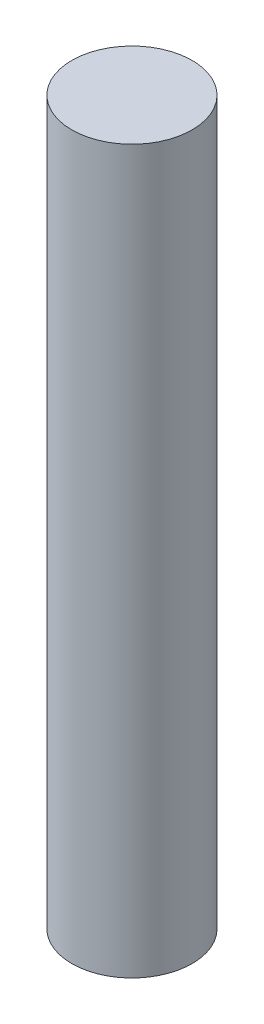
from build123d import *

# Parameters (mm, degrees)
SKETCH1_R           = 6.35
BOSS_EXTRUDE1_DEPTH = 76.2


with BuildPart() as part:
    # Sketch1 → Boss-Extrude1 (new body)
    with BuildSketch(Plane(origin=(0, 0, 0), x_dir=(1, 0, 0), z_dir=(0, 1, 0))):
        Circle(SKETCH1_R)
    extrude(amount=BOSS_EXTRUDE1_DEPTH)


solid = part.part
